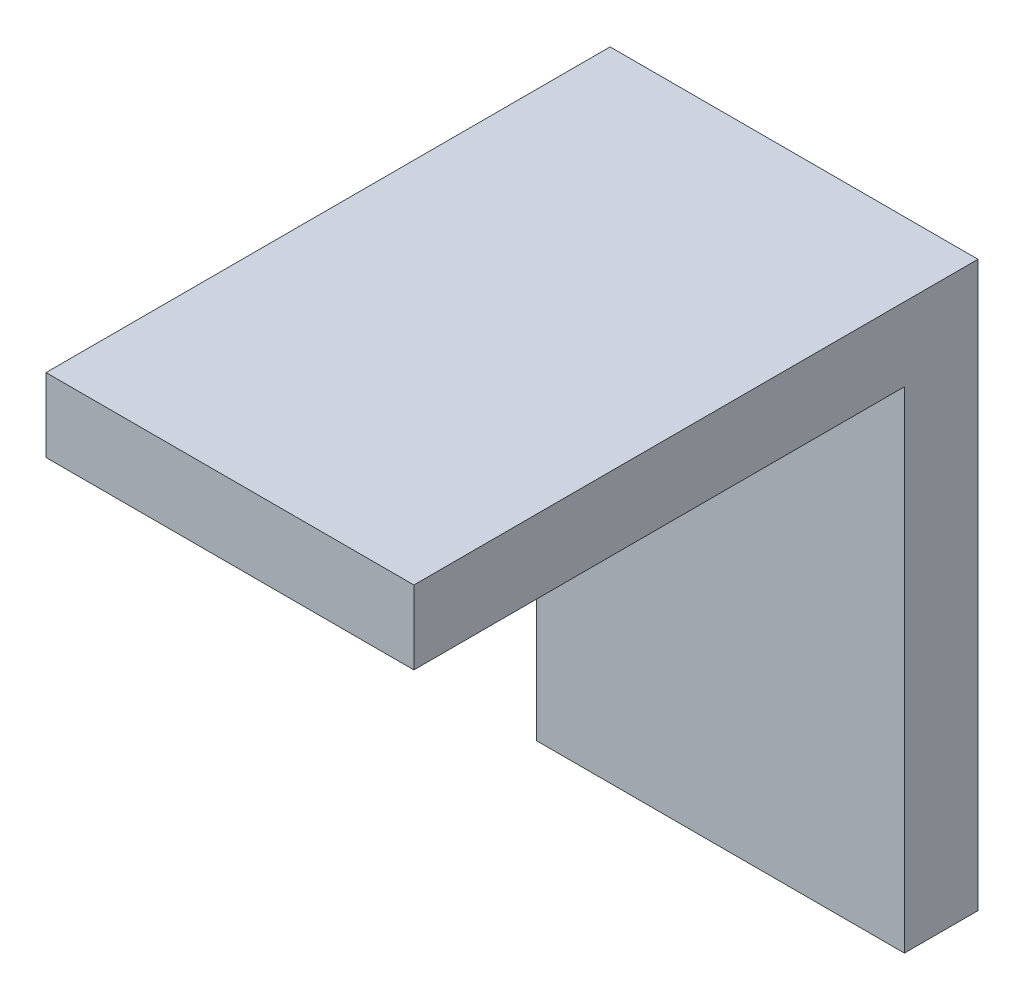
from build123d import *

# Parameters (mm, degrees)
EXTRUDE_THIN1_DEPTH = 30


with BuildPart() as part:
    # Sketch1 → Extrude-Thin1 (new body)
    with BuildSketch(Plane(origin=(0, 0, 0), x_dir=(0, 0, -1), z_dir=(1, 0, 0))):
        Polygon((-40, 0), (0, 0), (0, -40), (6, -40), (6, 6), (-40, 6), align=None)
    extrude(amount=EXTRUDE_THIN1_DEPTH)


solid = part.part
